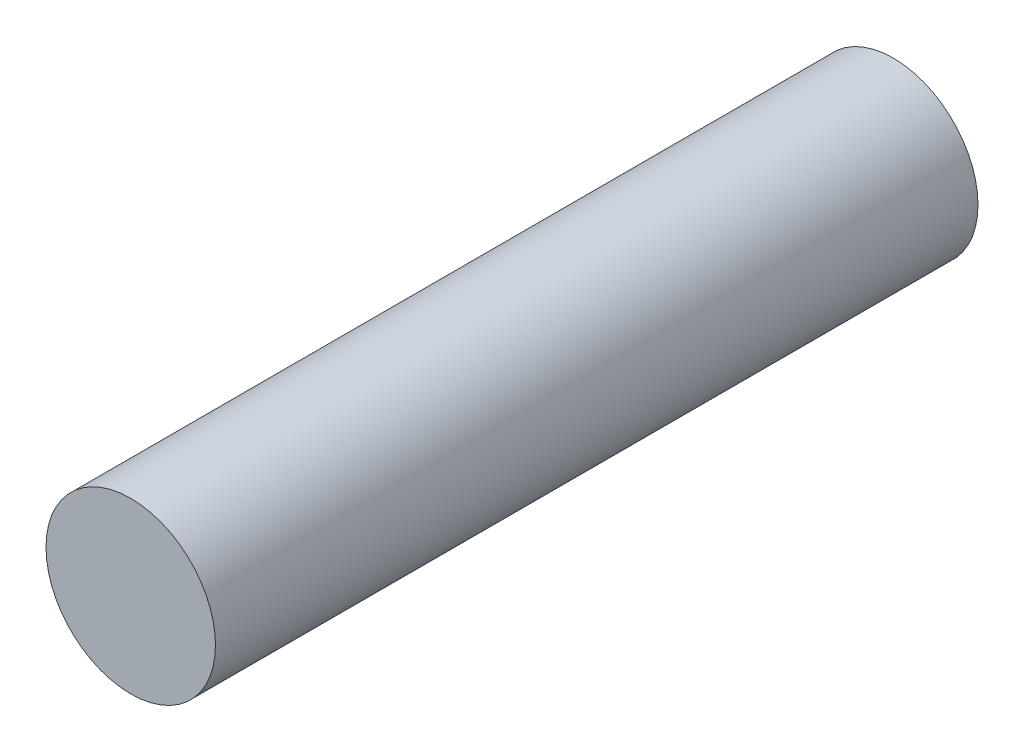
from build123d import *

# Parameters (mm, degrees)
SKETCH1_R          = 5
BASE_EXTRUDE_DEPTH = 45


with BuildPart() as part:
    # Sketch1 → Base-Extrude (new body)
    with BuildSketch(Plane.XY):
        Circle(SKETCH1_R)
    extrude(amount=BASE_EXTRUDE_DEPTH)


solid = part.part
